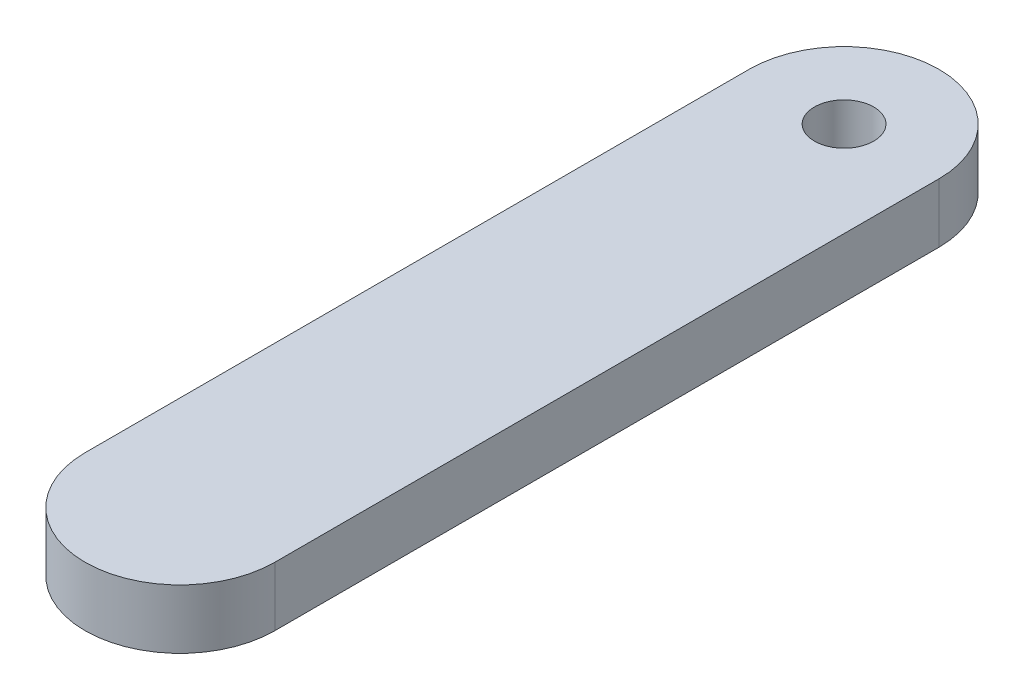
from build123d import *

# Parameters (mm, degrees)
SKETCH1_R           = 1.25
BOSS_EXTRUDE1_DEPTH = 2.5
SKETCH2_R           = 1.25
BOSS_EXTRUDE2_DEPTH = 1.25


with BuildPart() as part:
    # Sketch1 → Boss-Extrude1 (new body)
    with BuildSketch(Plane(origin=(0, 0, 0), x_dir=(1, 0, 0), z_dir=(0, 1, 0))):
        with BuildLine():
            Line((-4, 0), (-4, 28))
            ThreePointArc((-4, 28), (0, 32), (4, 28))
            Line((4, 28), (4, 0))
            ThreePointArc((4, 0), (0, -4), (-4, 0))
        make_face()
        with Locations((0, 28)):
            Circle(SKETCH1_R, mode=Mode.SUBTRACT)
    extrude(amount=BOSS_EXTRUDE1_DEPTH)

    # Sketch2 → Boss-Extrude2 (add)
    with BuildSketch(Plane.XZ):
        Circle(SKETCH2_R)
    extrude(amount=BOSS_EXTRUDE2_DEPTH)


solid = part.part
